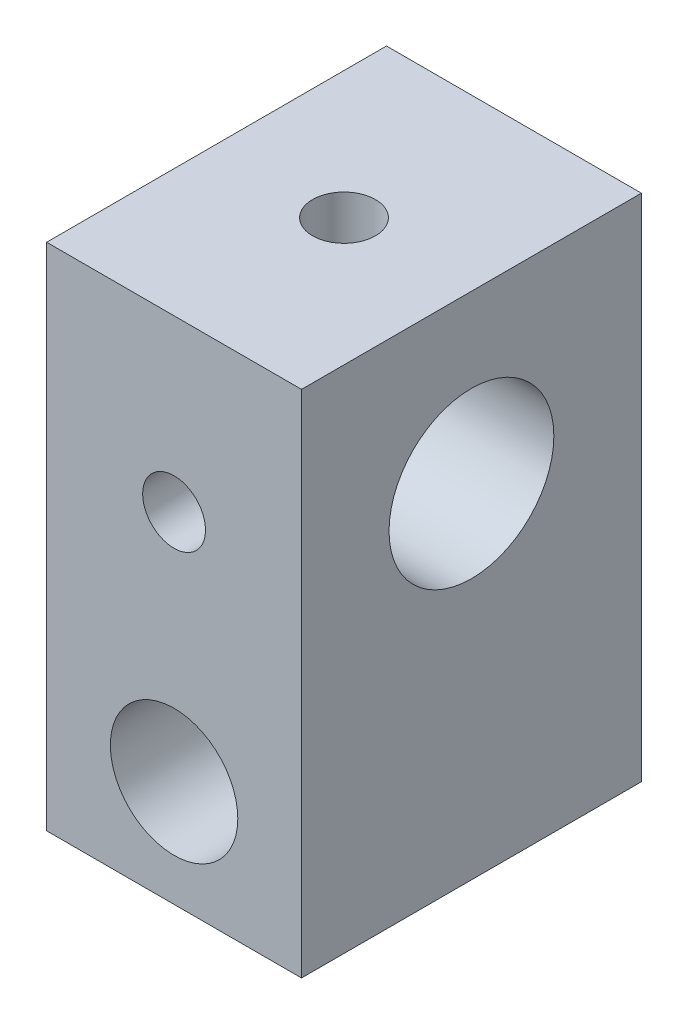
from build123d import *

# Parameters (mm, degrees)
SKETCH1_W           = 19.05
SKETCH1_H           = 25.4
BOSS_EXTRUDE1_DEPTH = 38.1
SKETCH2_R           = 4.7625
CUT_EXTRUDE1_DEPTH  = 26.4
SKETCH3_R           = 6.1595
CUT_EXTRUDE2_DEPTH  = 20.05
CUT_EXTRUDE3_REACH  = 40.1
SKETCH4_R           = 2.3495
SKETCH5_R           = 2.3495
CUT_EXTRUDE4_DEPTH  = 26.4


with BuildPart() as part:
    # Sketch1 → Boss-Extrude1 (new body)
    with BuildSketch(Plane(origin=(0, 0, 0), x_dir=(1, 0, 0), z_dir=(0, 1, 0))):
        Rectangle(SKETCH1_W, SKETCH1_H)
    extrude(amount=BOSS_EXTRUDE1_DEPTH)

    # Sketch2 → Cut-Extrude1 (cut, through all)
    with BuildSketch(Plane.XY.offset(12.7)):
        with Locations((0, 7.9375)):
            Circle(SKETCH2_R)
    extrude(amount=-CUT_EXTRUDE1_DEPTH, mode=Mode.SUBTRACT)

    # Sketch3 → Cut-Extrude2 (cut, through all)
    with BuildSketch(Plane(origin=(9.525, 0, 0), x_dir=(0, 0, -1), z_dir=(1, 0, 0))):
        with Locations((0, 25.654)):
            Circle(SKETCH3_R)
    extrude(amount=-CUT_EXTRUDE2_DEPTH, mode=Mode.SUBTRACT)

    # Sketch4 → Cut-Extrude3 (cut, up to next)
    with BuildSketch(Plane(origin=(0, 38.1, 0), x_dir=(1, 0, 0), z_dir=(0, 1, 0)), mode=Mode.PRIVATE) as cut_extrude3_sk1:
        Circle(SKETCH4_R)
    cut_extrude3_tool1 = extrude(cut_extrude3_sk1.sketch, amount=-CUT_EXTRUDE3_REACH, mode=Mode.PRIVATE) & part.part
    add(cut_extrude3_tool1.solids().sort_by_distance((0, 38.1, 0))[0], mode=Mode.SUBTRACT)

    # Sketch5 → Cut-Extrude4 (cut, through all)
    with BuildSketch(Plane(origin=(0, 0, -12.7), x_dir=(-1, 0, 0), z_dir=(0, 0, -1))):
        with Locations((0, 25.4)):
            Circle(SKETCH5_R)
    extrude(amount=-CUT_EXTRUDE4_DEPTH, mode=Mode.SUBTRACT)


solid = part.part
